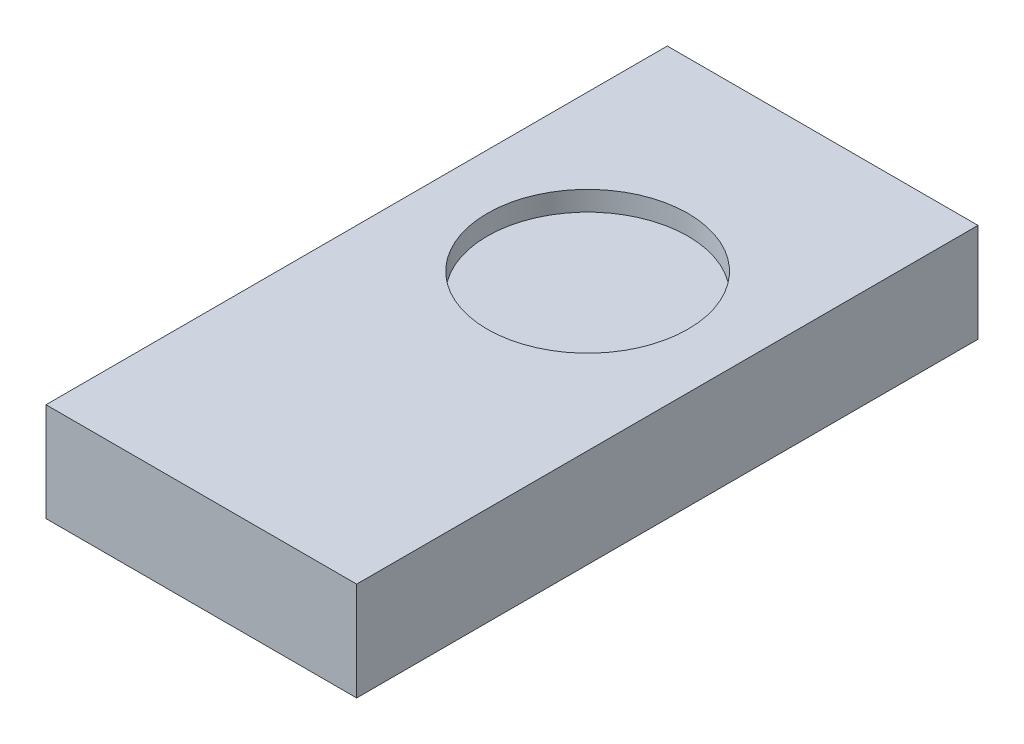
from build123d import *

# Parameters (mm, degrees)
SKETCH1_W           = 10
SKETCH1_H           = 20
BOSS_EXTRUDE1_DEPTH = 3.175
SKETCH2_R           = 3.230323421
CUT_EXTRUDE1_DEPTH  = 0.635


with BuildPart() as part:
    # Sketch1 → Boss-Extrude1 (new body)
    with BuildSketch(Plane(origin=(0, 0, 0), x_dir=(1, 0, 0), z_dir=(0, 1, 0))):
        with Locations((5, 10)):
            Rectangle(SKETCH1_W, SKETCH1_H)
    extrude(amount=BOSS_EXTRUDE1_DEPTH)

    # Sketch2 → Cut-Extrude1 (cut)
    with BuildSketch(Plane(origin=(0, 3.175, 0), x_dir=(1, 0, 0), z_dir=(0, 1, 0))):
        with Locations((4.996452047, 12.437024889)):
            Circle(SKETCH2_R)
    extrude(amount=-CUT_EXTRUDE1_DEPTH, mode=Mode.SUBTRACT)


solid = part.part
